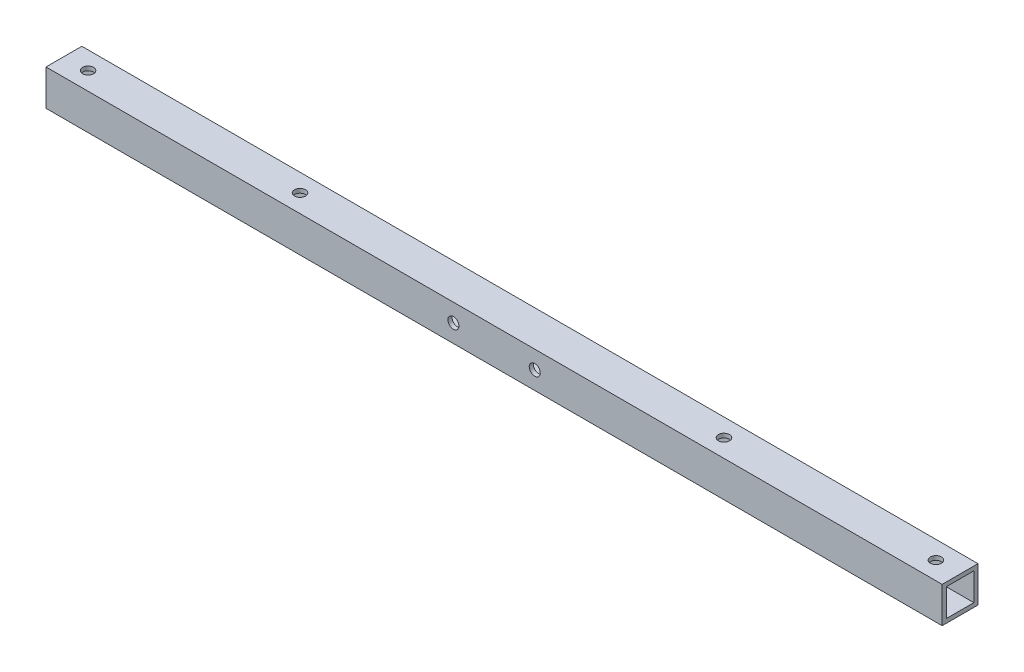
from build123d import *

# Parameters (mm, degrees)
SKETCH1_W           = 650
SKETCH1_H           = 26
BOSS_EXTRUDE1_DEPTH = 26
SHELL1_T            = -3
SKETCH2_R           = 4
CUT_EXTRUDE1_DEPTH  = 26
SKETCH3_R           = 4
CUT_EXTRUDE2_DEPTH  = 27


with BuildPart() as part:
    # Sketch1 → Boss-Extrude1 (new body)
    with BuildSketch(Plane(origin=(0, 0, 0), x_dir=(1, 0, 0), z_dir=(0, 1, 0))):
        Rectangle(SKETCH1_W, SKETCH1_H)
    extrude(amount=BOSS_EXTRUDE1_DEPTH)

    # Shell1
    shell1_openings = [part.faces().sort_by_distance(p)[0] for p in [
        (-325, 13, 0),
        (325, 13, 0),
    ]]
    offset(amount=SHELL1_T, openings=shell1_openings, kind=Kind.INTERSECTION)

    # Sketch2 → Cut-Extrude1 (cut)
    with BuildSketch(Plane(origin=(0, 26, 0), x_dir=(1, 0, 0), z_dir=(0, 1, 0))):
        with Locations((307.5, 0)):
            Circle(SKETCH2_R)
        with Locations((-307.5, 0)):
            Circle(SKETCH2_R)
        with Locations((153.75, 0)):
            Circle(SKETCH2_R)
        with Locations((-153.75, 0)):
            Circle(SKETCH2_R)
    extrude(amount=-CUT_EXTRUDE1_DEPTH, mode=Mode.SUBTRACT)

    # Sketch3 → Cut-Extrude2 (cut, through all)
    with BuildSketch(Plane.XY.offset(13)):
        with Locations((-29.5, 13)):
            Circle(SKETCH3_R)
        with Locations((29.5, 13)):
            Circle(SKETCH3_R)
    extrude(amount=-CUT_EXTRUDE2_DEPTH, mode=Mode.SUBTRACT)


solid = part.part
